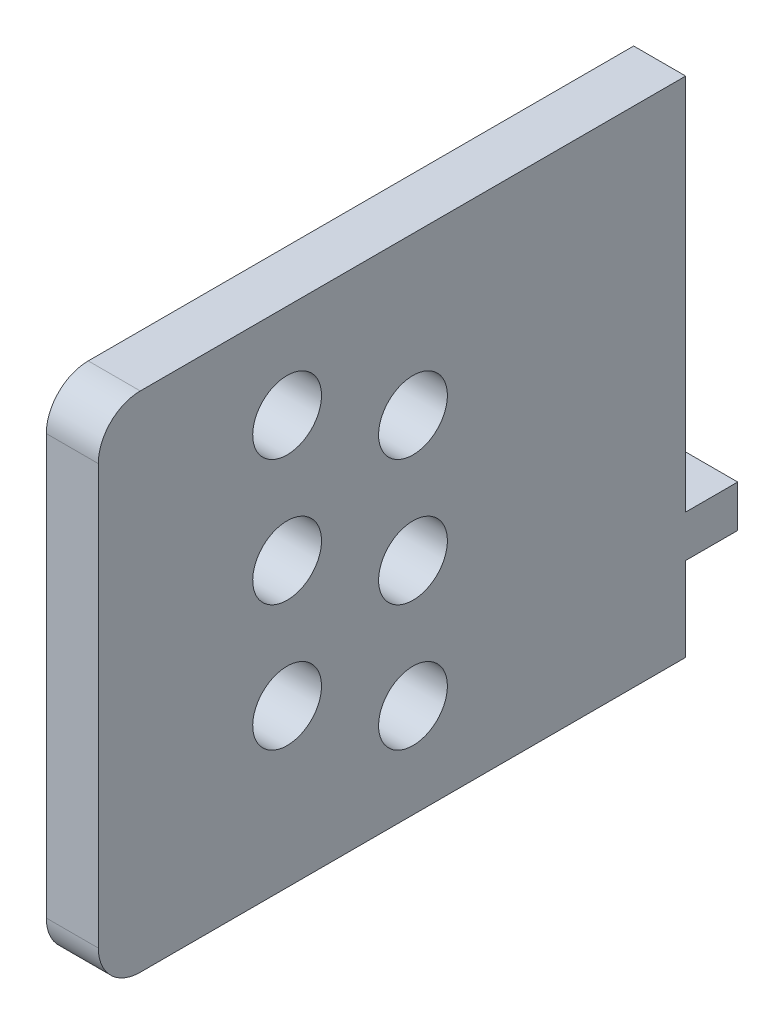
from build123d import *

# Parameters (mm, degrees)
SKETCH1_W          = 7.874
SKETCH1_H          = 76.2
EXTRUDE1_DEPTH     = 88.9
SKETCH2_R          = 5.207
CUT_EXTRUDE1_DEPTH = 8.874
FILLET1_R          = 6.35
SKETCH3_W          = 7.874
SKETCH3_H          = 6.35
EXTRUDE2_DEPTH     = 7.874


with BuildPart() as part:
    # Sketch1 → Extrude1 (new body)
    with BuildSketch(Plane.XY):
        with Locations((3.937, 38.1)):
            Rectangle(SKETCH1_W, SKETCH1_H)
    extrude(amount=EXTRUDE1_DEPTH)

    # Sketch2 → Cut-Extrude1 (cut, through all)
    with BuildSketch(Plane.ZY):
        with Locations((60.325, 23.8125)):
            Circle(SKETCH2_R)
        with Locations((60.325, 42.8625)):
            Circle(SKETCH2_R)
        with Locations((60.325, 61.9125)):
            Circle(SKETCH2_R)
        with Locations((41.275, 33.3375)):
            Circle(SKETCH2_R)
        with Locations((41.275, 52.3875)):
            Circle(SKETCH2_R)
        with Locations((41.275, 14.2875)):
            Circle(SKETCH2_R)
    extrude(amount=-CUT_EXTRUDE1_DEPTH, mode=Mode.SUBTRACT)

    # Fillet1
    fillet1_edges = [part.edges().sort_by_distance(p)[0] for p in [
        (3.937, 76.2, 88.9),
        (3.937, 0, 88.9),
    ]]
    fillet(fillet1_edges, radius=FILLET1_R)

    # Sketch3 → Extrude2 (add)
    with BuildSketch(Plane.XY):
        with Locations((3.937, 15.875)):
            Rectangle(SKETCH3_W, SKETCH3_H)
    extrude(amount=-EXTRUDE2_DEPTH)


solid = part.part
